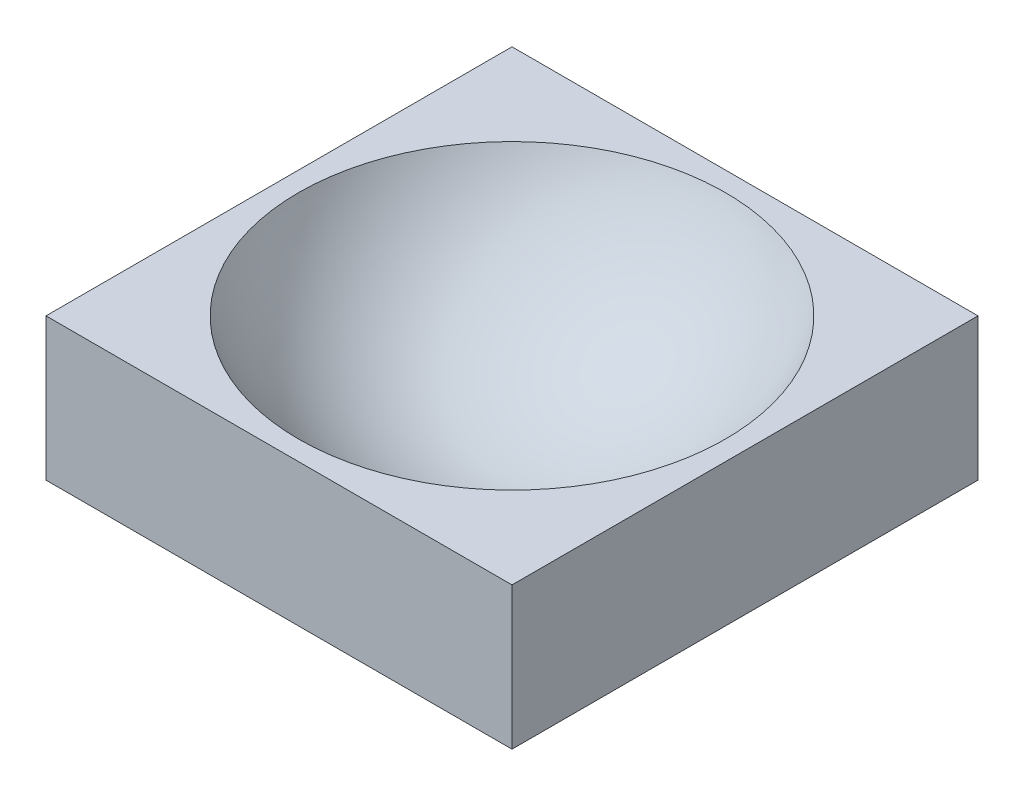
from build123d import *

# Parameters (mm, degrees)
SKETCH1_W           = 238.3
SKETCH1_H           = 238.3
BOSS_EXTRUDE1_DEPTH = 72.766666667


with BuildPart() as part:
    # Sketch1 → Boss-Extrude1 (new body)
    with BuildSketch(Plane(origin=(0, 0, 0), x_dir=(1, 0, 0), z_dir=(0, 1, 0))):
        Rectangle(SKETCH1_W, SKETCH1_H)
    extrude(amount=BOSS_EXTRUDE1_DEPTH)

    # Sketch3 → Cut-Revolve8 (revolve, cut)
    with BuildSketch(Plane.XY):
        with BuildLine():
            Line((-109.15, 72.766666667), (0, 72.766666667))
            Line((0, 72.766666667), (0, 10))
            Line((0, 10), (0, 0.553473444))
            ThreePointArc((0, 0.553473444), (-65.437886151, 20.240853976), (-109.15, 72.766666667))
        make_face()
    revolve(axis=Axis((0, 72.766666667, 0), (0, -1, 0)), mode=Mode.SUBTRACT)


solid = part.part
